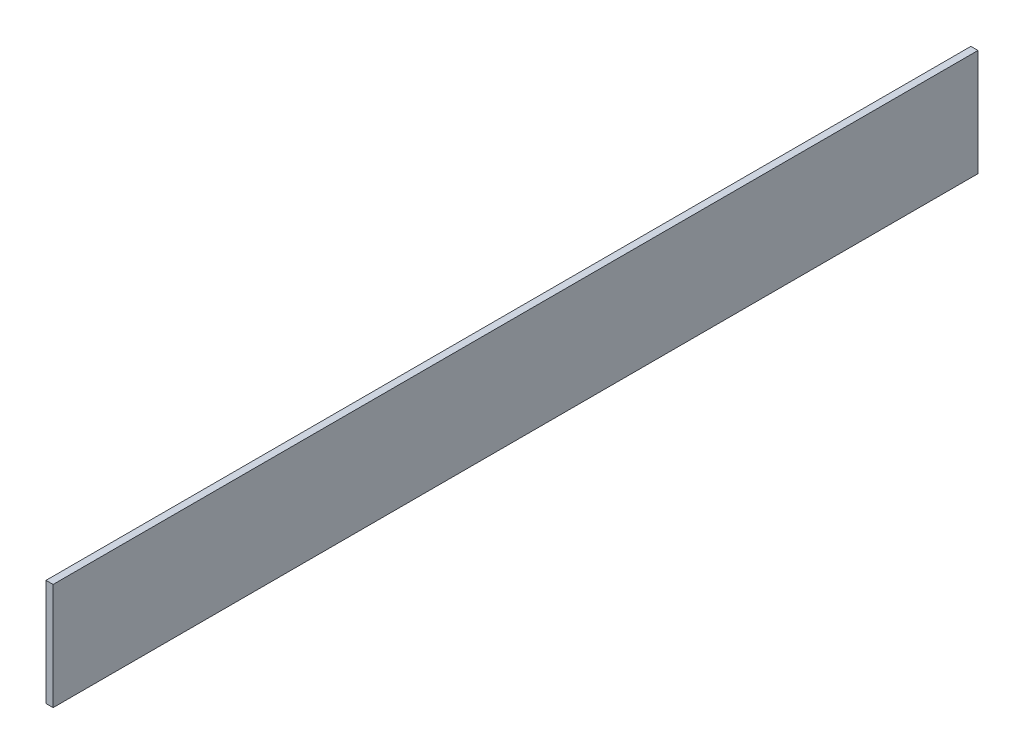
from build123d import *

# Parameters (mm, degrees)
SKIZZE1_W                    = 1
SKIZZE1_H                    = 130
LINEAR_AUSTRAGEN_D_NN1_DEPTH = 15


with BuildPart() as part:
    # Skizze1 → Linear-Austragen-Dünn1 (new body)
    with BuildSketch(Plane(origin=(0, 20, 0), x_dir=(1, 0, 0), z_dir=(0, 1, 0))):
        with Locations((149.5, 10)):
            Rectangle(SKIZZE1_W, SKIZZE1_H)
    extrude(amount=LINEAR_AUSTRAGEN_D_NN1_DEPTH)


solid = part.part
